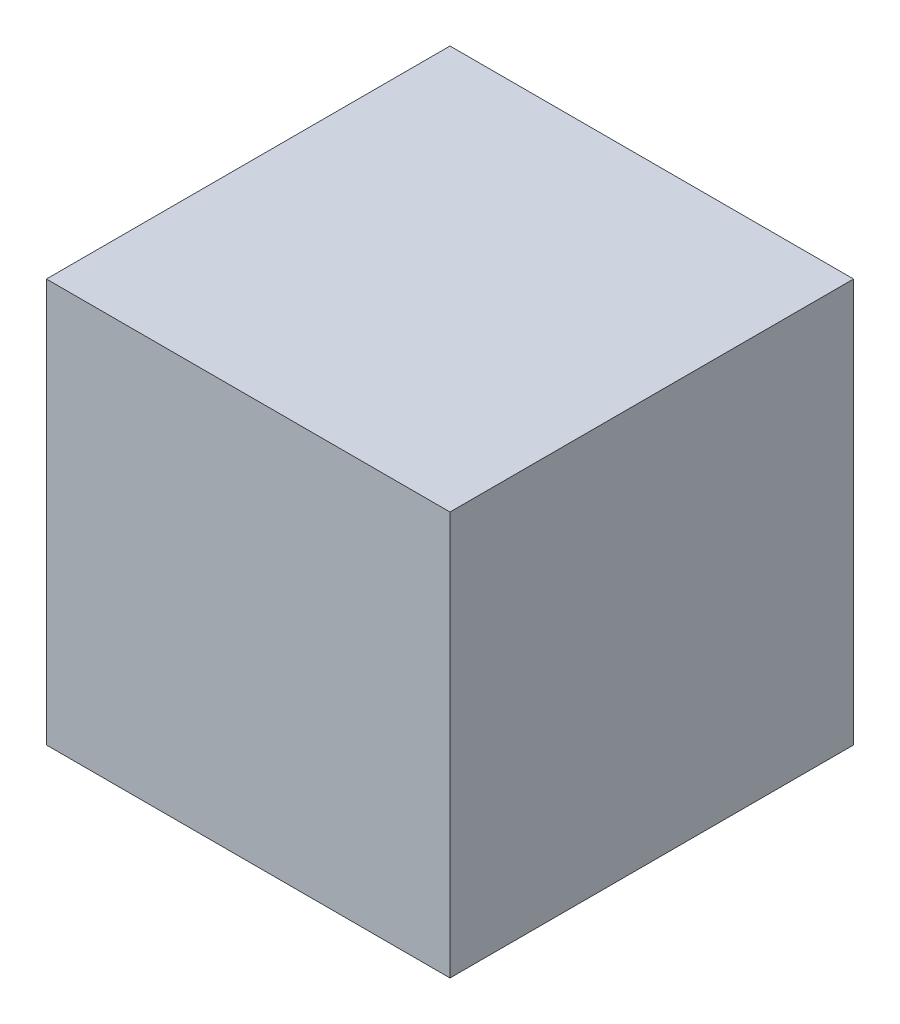
from build123d import *

# Parameters (mm, degrees)
SKETCH1_W           = 12.7
SKETCH1_H           = 12.7
BOSS_EXTRUDE1_DEPTH = 12.7


with BuildPart() as part:
    # Sketch1 → Boss-Extrude1 (new body)
    with BuildSketch(Plane(origin=(0, 0, 0), x_dir=(1, 0, 0), z_dir=(0, 1, 0))):
        with Locations((6.35, 6.35)):
            Rectangle(SKETCH1_W, SKETCH1_H)
    extrude(amount=BOSS_EXTRUDE1_DEPTH)


solid = part.part
